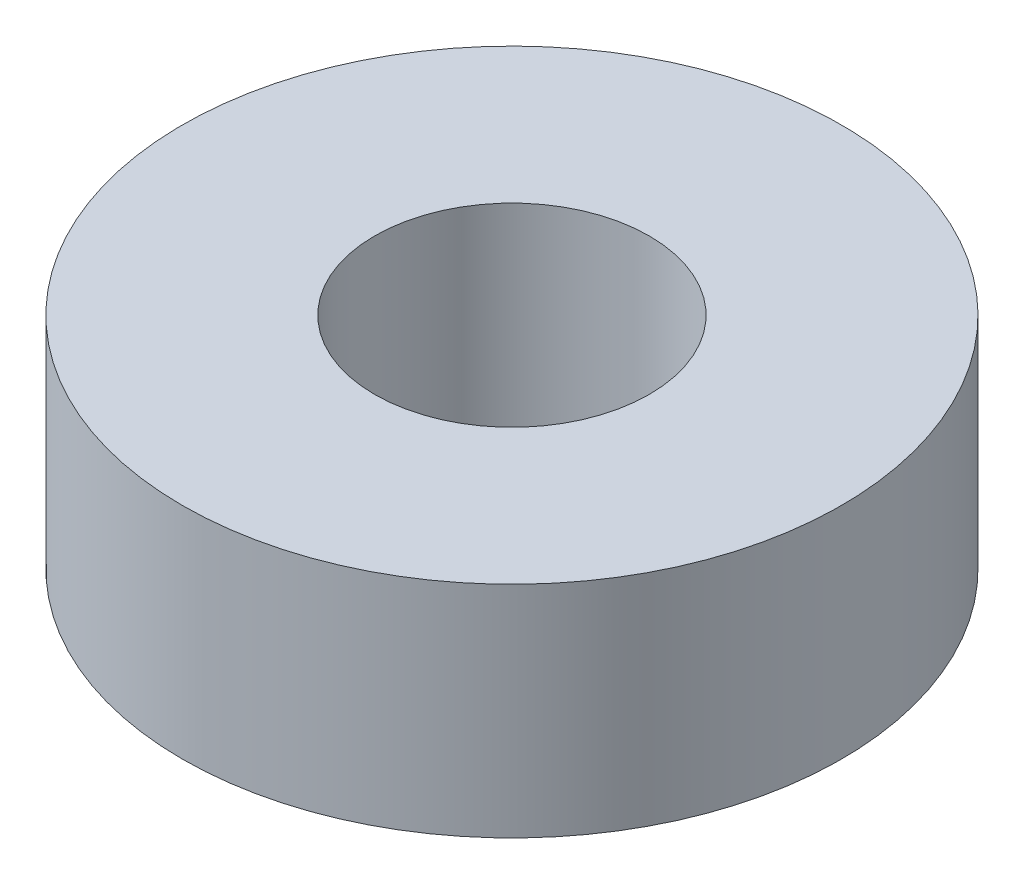
from build123d import *

# Parameters (mm, degrees)
SKETCH1_R           = 6
SKETCH1_R_2         = 2.5
BOSS_EXTRUDE1_DEPTH = 4


with BuildPart() as part:
    # Sketch1 → Boss-Extrude1 (new body)
    with BuildSketch(Plane(origin=(0, 0, 0), x_dir=(1, 0, 0), z_dir=(0, 1, 0))):
        Circle(SKETCH1_R)
        Circle(SKETCH1_R_2, mode=Mode.SUBTRACT)
    extrude(amount=BOSS_EXTRUDE1_DEPTH)


solid = part.part
